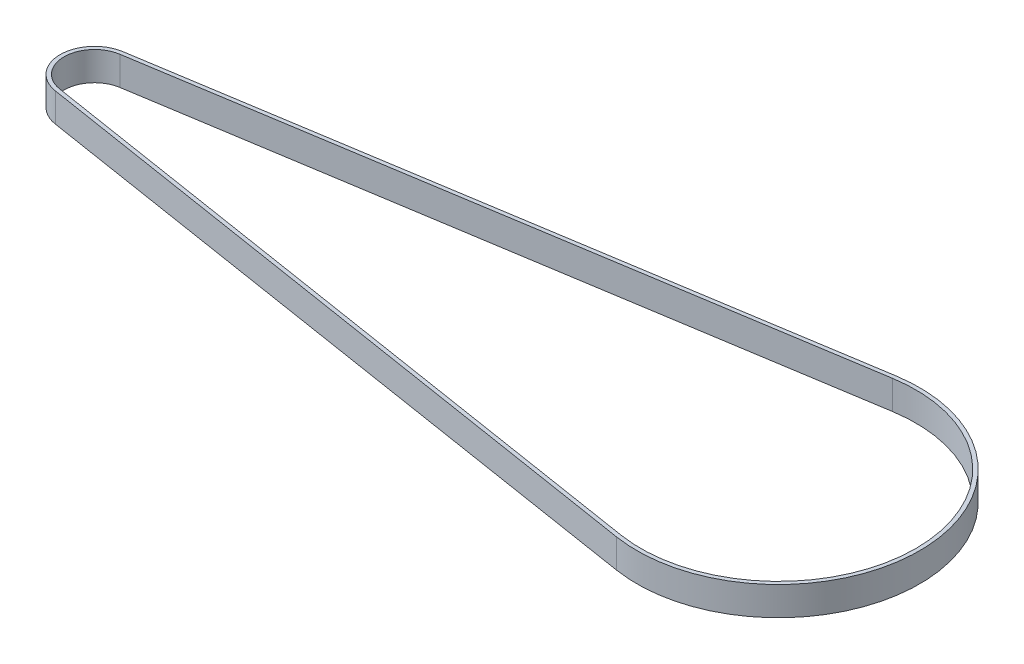
from build123d import *

# Parameters (mm, degrees)
BOSS_EXTRUDE1_DEPTH = 6


with BuildPart() as part:
    # Sketch1 → Boss-Extrude1 (new body)
    with BuildSketch(Plane(origin=(0, 0, 0), x_dir=(1, 0, 0), z_dir=(0, 1, 0))):
        with BuildLine():
            Line((-143.618912281, 7.061907342), (-4.608666667, 29.087156815))
            ThreePointArc((-4.608666667, 29.087156815), (29.45, 0), (-4.608666667, -29.087156815))
            Line((-4.608666667, -29.087156815), (-143.618912281, -7.061907342))
            ThreePointArc((-143.618912281, -7.061907342), (-149.65, 0), (-143.618912281, 7.061907342))
        make_face()
        with BuildLine():
            Line((-143.493719298, 6.271763863), (-4.483473684, 28.297013336))
            ThreePointArc((-4.483473684, 28.297013336), (28.65, 0), (-4.483473684, -28.297013336))
            Line((-4.483473684, -28.297013336), (-143.493719298, -6.271763863))
            ThreePointArc((-143.493719298, -6.271763863), (-148.85, 0), (-143.493719298, 6.271763863))
        make_face(mode=Mode.SUBTRACT)
    extrude(amount=BOSS_EXTRUDE1_DEPTH)


solid = part.part
